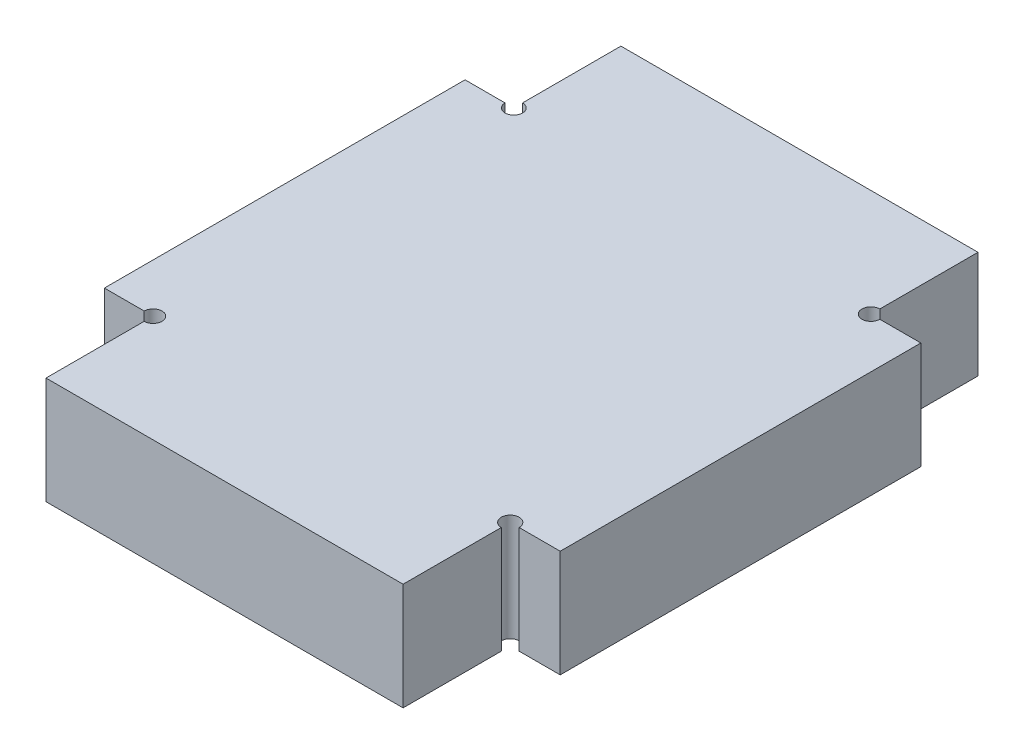
from build123d import *

# Parameters (mm, degrees)
BOSS_EXTRUDE1_DEPTH = 3


with BuildPart() as part:
    # Sketch1 → Boss-Extrude1 (new body)
    with BuildSketch(Plane(origin=(0, 0, 0), x_dir=(1, 0, 0), z_dir=(0, 1, 0))):
        with BuildLine():
            Line((0.25, 5.332122905), (1.4, 5.332122905))
            Line((1.4, 5.332122905), (1.4, -4.767877095))
            Line((1.4, -4.767877095), (0.25, -4.767877095))
            ThreePointArc((0.25, -4.767877095), (-0.176776695, -4.5911004), (0, -5.017877095))
            Line((0, -5.017877095), (0, -7.767877095))
            Line((0, -7.767877095), (-10, -7.767877095))
            Line((-10, -7.767877095), (-10, -5.017877095))
            ThreePointArc((-10, -5.017877095), (-9.823223305, -4.5911004), (-10.25, -4.767877095))
            Line((-10.25, -4.767877095), (-11.364691425, -4.767877095))
            Line((-11.364691425, -4.767877095), (-11.364691425, 5.332122905))
            Line((-11.364691425, 5.332122905), (-10.245259273, 5.332122905))
            ThreePointArc((-10.245259273, 5.332122905), (-9.826575505, 5.15869841), (-10, 5.577382178))
            Line((-10, 5.577382178), (-10, 8.332122905))
            Line((-10, 8.332122905), (0, 8.332122905))
            Line((0, 8.332122905), (0, 5.582122905))
            ThreePointArc((0, 5.582122905), (-0.176776695, 5.15534621), (0.25, 5.332122905))
        make_face()
    extrude(amount=BOSS_EXTRUDE1_DEPTH)


solid = part.part
